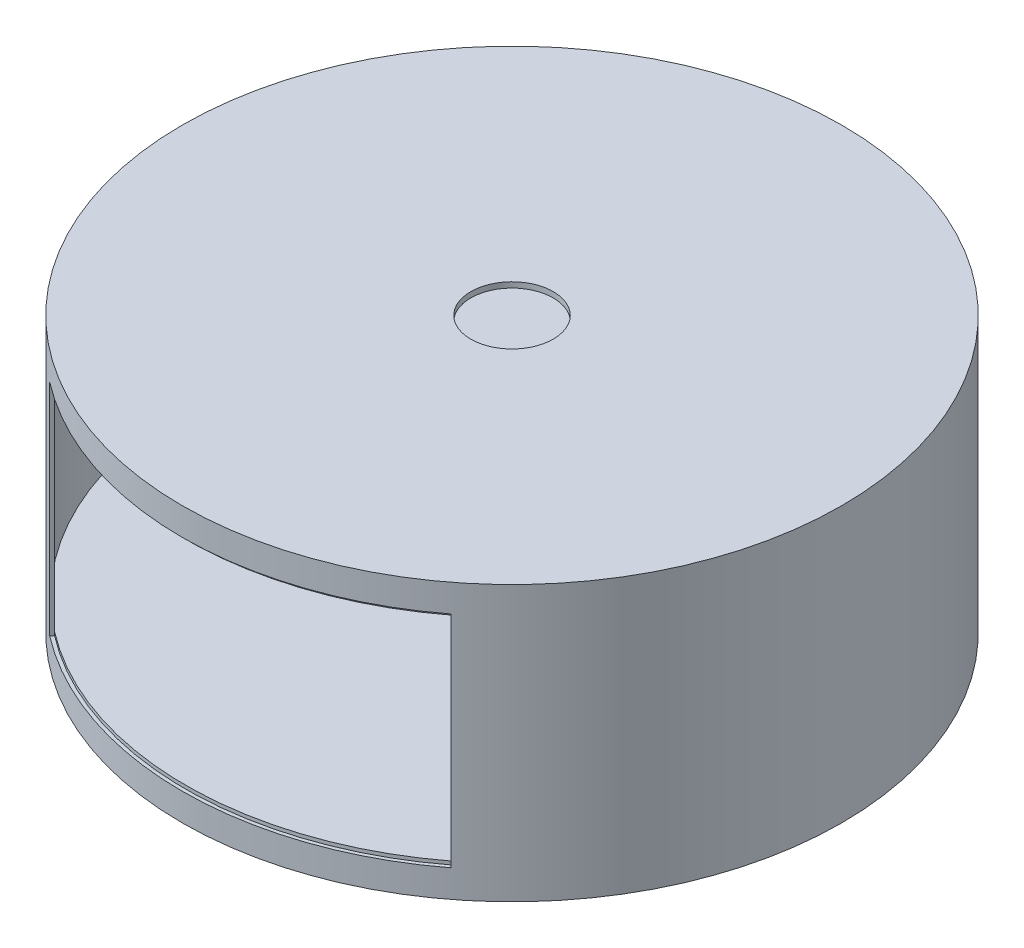
from build123d import *

# Parameters (mm, degrees)
SKETCH1_R           = 152.4
BOSS_EXTRUDE1_DEPTH = 63.5
SKETCH2_R           = 150.8125
CUT_EXTRUDE1_DEPTH  = 49.2125
SKETCH3_W           = 1.5875
SKETCH3_H           = 101.6
CUT_REVOLVE1_ANGLE  = 75
SKETCH4_R           = 19.05
CUT_EXTRUDE2_DEPTH  = 2.54


with BuildPart() as part:
    # Sketch1 → Boss-Extrude1 (new body, symmetric)
    with BuildSketch(Plane(origin=(0, 0, 0), x_dir=(1, 0, 0), z_dir=(0, 1, 0))):
        Circle(SKETCH1_R)
    extrude(amount=BOSS_EXTRUDE1_DEPTH, both=True)

    # Sketch2 → Cut-Extrude1 (cut, symmetric)
    with BuildSketch(Plane(origin=(0, 0, 0), x_dir=(1, 0, 0), z_dir=(0, 1, 0))):
        Circle(SKETCH2_R)
    extrude(amount=CUT_EXTRUDE1_DEPTH, both=True, mode=Mode.SUBTRACT)

    # Sketch3 → Cut-Revolve1 (revolve, symmetric, cut)
    with BuildSketch(Plane(origin=(0, 0, 0), x_dir=(0, 0, -1), z_dir=(1, 0, 0))) as cut_revolve1_sk:
        with Locations((-151.60625, 0)):
            Rectangle(SKETCH3_W, SKETCH3_H)
    revolve(axis=Axis((0, 0, 0), (0, 1, 0)), revolution_arc=CUT_REVOLVE1_ANGLE / 2, mode=Mode.SUBTRACT)
    revolve(cut_revolve1_sk.sketch, axis=Axis((0, 0, 0), (0, -1, 0)), revolution_arc=CUT_REVOLVE1_ANGLE / 2, mode=Mode.SUBTRACT)

    # Sketch4 → Cut-Extrude2 (cut)
    with BuildSketch(Plane(origin=(0, 63.5, 0), x_dir=(1, 0, 0), z_dir=(0, 1, 0))):
        Circle(SKETCH4_R)
    extrude(amount=-CUT_EXTRUDE2_DEPTH, mode=Mode.SUBTRACT)


solid = part.part
